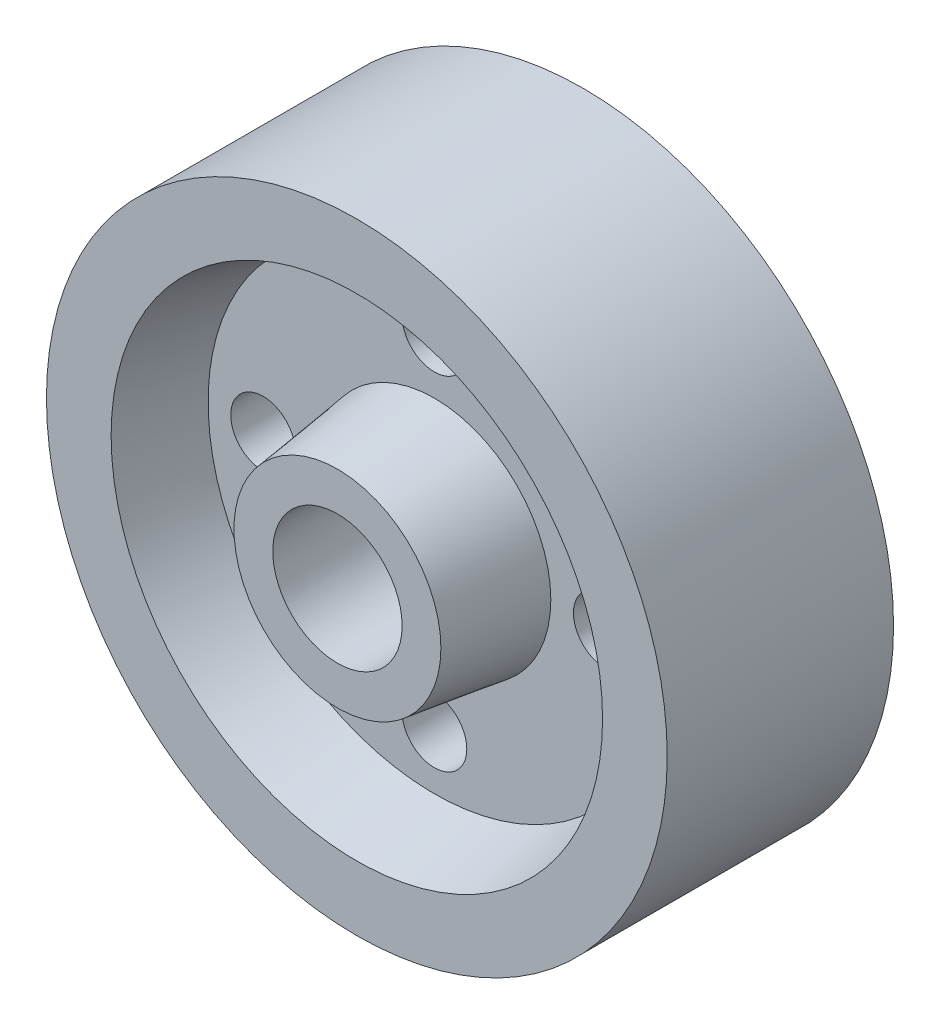
from build123d import *

# Parameters (mm, degrees)
SKETCH2_R          = 5
CUT_EXTRUDE1_DEPTH = 27


with BuildPart() as part:
    # Sketch1 → Revolve1 (revolve)
    with BuildSketch(Plane(origin=(0, 0, 0), x_dir=(0, 0, -1), z_dir=(1, 0, 0))):
        Polygon((-17.5, 48), (17.5, 48), (17.5, 38), (5.5, 35), (-5.5, 35), (-17.5, 38), align=None)
        Polygon((-5.5, 18), (-5.5, 10), (5.5, 10), (5.5, 18), (5.5, 35), (-5.5, 35), align=None)
        Polygon((5.5, 18), (5.5, 10), (20.5, 10), (20.5, 16), align=None)
        Polygon((-20.5, 16), (-20.5, 10), (-5.5, 10), (-5.5, 18), align=None)
    revolve(axis=Axis((0, 0, 20.5), (0, 0, -1)))

    # Sketch2 → Cut-Extrude1 (cut, through all)
    with BuildSketch(Plane(origin=(0, 0, -5.5), x_dir=(-1, 0, 0), z_dir=(0, 0, -1))):
        with Locations((0, 26.5)):
            Circle(SKETCH2_R)
        with Locations((26.5, 0)):
            Circle(SKETCH2_R)
        with Locations((0, -26.5)):
            Circle(SKETCH2_R)
        with Locations((-26.5, 0)):
            Circle(SKETCH2_R)
    extrude(amount=-CUT_EXTRUDE1_DEPTH, mode=Mode.SUBTRACT)


solid = part.part
